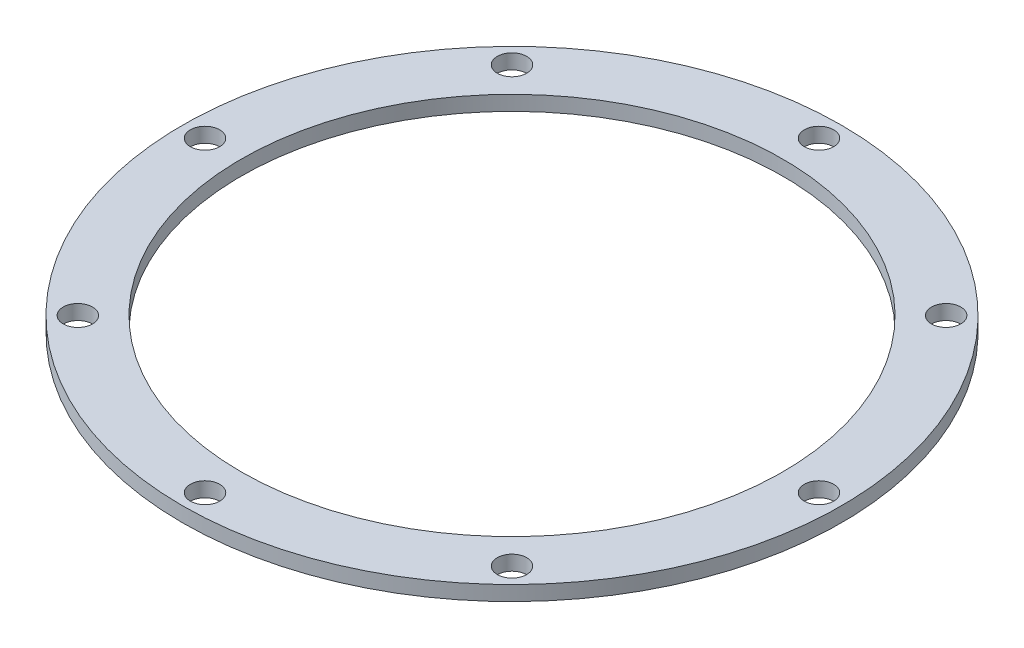
from build123d import *

# Parameters (mm, degrees)
SKETCH1_R           = 73
SKETCH1_R_2         = 60
SKETCH1_R_3         = 3.25
BOSS_EXTRUDE1_DEPTH = 3.275


with BuildPart() as part:
    # Sketch1 → Boss-Extrude1 (new body)
    with BuildSketch(Plane(origin=(0, 0, 0), x_dir=(1, 0, 0), z_dir=(0, 1, 0))):
        Circle(SKETCH1_R)
        Circle(SKETCH1_R_2, mode=Mode.SUBTRACT)
        with Locations((-48.083261121, 48.083261121)):
            Circle(SKETCH1_R_3, mode=Mode.SUBTRACT)
        with Locations((-68, 0)):
            Circle(SKETCH1_R_3, mode=Mode.SUBTRACT)
        with Locations((0, 68)):
            Circle(SKETCH1_R_3, mode=Mode.SUBTRACT)
        with Locations((48.083261121, 48.083261121)):
            Circle(SKETCH1_R_3, mode=Mode.SUBTRACT)
        with Locations((68, 0)):
            Circle(SKETCH1_R_3, mode=Mode.SUBTRACT)
        with Locations((48.083261121, -48.083261121)):
            Circle(SKETCH1_R_3, mode=Mode.SUBTRACT)
        with Locations((0, -68)):
            Circle(SKETCH1_R_3, mode=Mode.SUBTRACT)
        with Locations((-48.083261121, -48.083261121)):
            Circle(SKETCH1_R_3, mode=Mode.SUBTRACT)
    extrude(amount=BOSS_EXTRUDE1_DEPTH)


solid = part.part
